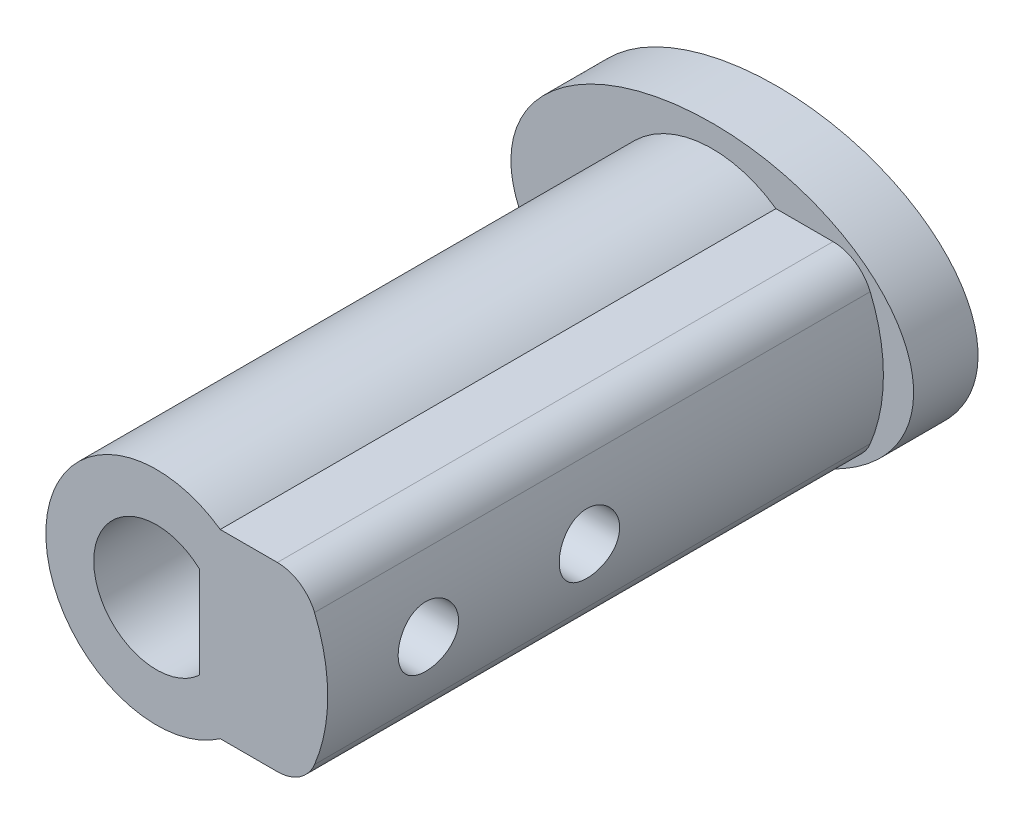
from build123d import *

# Parameters (mm, degrees)
BOSS_EXTRUDE1_DEPTH = 13.8
CUT_EXTRUDE1_DEPTH  = 8.3
SKETCH5_R           = 0.75
CUT_EXTRUDE3_DEPTH  = 4.5
SKETCH7_RX          = 5
SKETCH7_RY          = 3.3
BOSS_EXTRUDE5_DEPTH = 1.6
FILLET1_R           = 1
CUT_EXTRUDE4_DEPTH  = 8.3


with BuildPart() as part:
    # Sketch1 → Boss-Extrude1 (new body)
    with BuildSketch(Plane.XY):
        with BuildLine():
            Line((1.58113883, -2.25), (3.605551275, -2.25))
            ThreePointArc((3.605551275, -2.25), (4.25, 0), (3.605551275, 2.25))
            Line((3.605551275, 2.25), (1.58113883, 2.25))
            ThreePointArc((1.58113883, 2.25), (-2.75, 0), (1.58113883, -2.25))
        make_face()
    extrude(amount=BOSS_EXTRUDE1_DEPTH)

    # Sketch3 → Cut-Extrude1 (cut)
    with BuildSketch(Plane.XY.offset(13.8)):
        with BuildLine():
            Line((1, -1.118033989), (1, 1.118033989))
            ThreePointArc((1, 1.118033989), (-1.5, 0), (1, -1.118033989))
        make_face()
    extrude(amount=-CUT_EXTRUDE1_DEPTH, mode=Mode.SUBTRACT)

    # Sketch5 → Cut-Extrude3 (cut)
    with BuildSketch(Plane(origin=(4.25, 0, 0), x_dir=(0, 0, -1), z_dir=(1, 0, 0))):
        with Locations((-11.3, 0)):
            Circle(SKETCH5_R)
        with Locations((-7.3, 0)):
            Circle(SKETCH5_R)
    extrude(amount=-CUT_EXTRUDE3_DEPTH, mode=Mode.SUBTRACT)

    # Sketch7 → Boss-Extrude5 (add)
    with BuildSketch(Plane(origin=(0, 0, 0), x_dir=(-1, 0, 0), z_dir=(0, 0, -1))):
        with Locations(Location((0, 0), (0, 0, 0))):
            Ellipse(SKETCH7_RX, SKETCH7_RY)
    extrude(amount=BOSS_EXTRUDE5_DEPTH)

    # Fillet1
    fillet1_edges = [part.edges().sort_by_distance(p)[0] for p in [
        (3.605551275, -2.25, 6.9),
        (3.605551275, 2.25, 6.9),
    ]]
    fillet(fillet1_edges, radius=FILLET1_R)

    # Sketch8 → Cut-Extrude4 (cut)
    with BuildSketch(Plane.XY.offset(13.8)):
        with BuildLine():
            Line((1.06, 1.144552314), (1.06, -1.144552314))
            ThreePointArc((1.06, -1.144552314), (-1.56, 0), (1.06, 1.144552314))
        make_face()
        with BuildLine():
            Line((1, 1.118033989), (1, -1.118033989))
            ThreePointArc((1, -1.118033989), (-1.5, 0), (1, 1.118033989))
        make_face(mode=Mode.SUBTRACT)
    extrude(amount=-CUT_EXTRUDE4_DEPTH, mode=Mode.SUBTRACT)


solid = part.part
